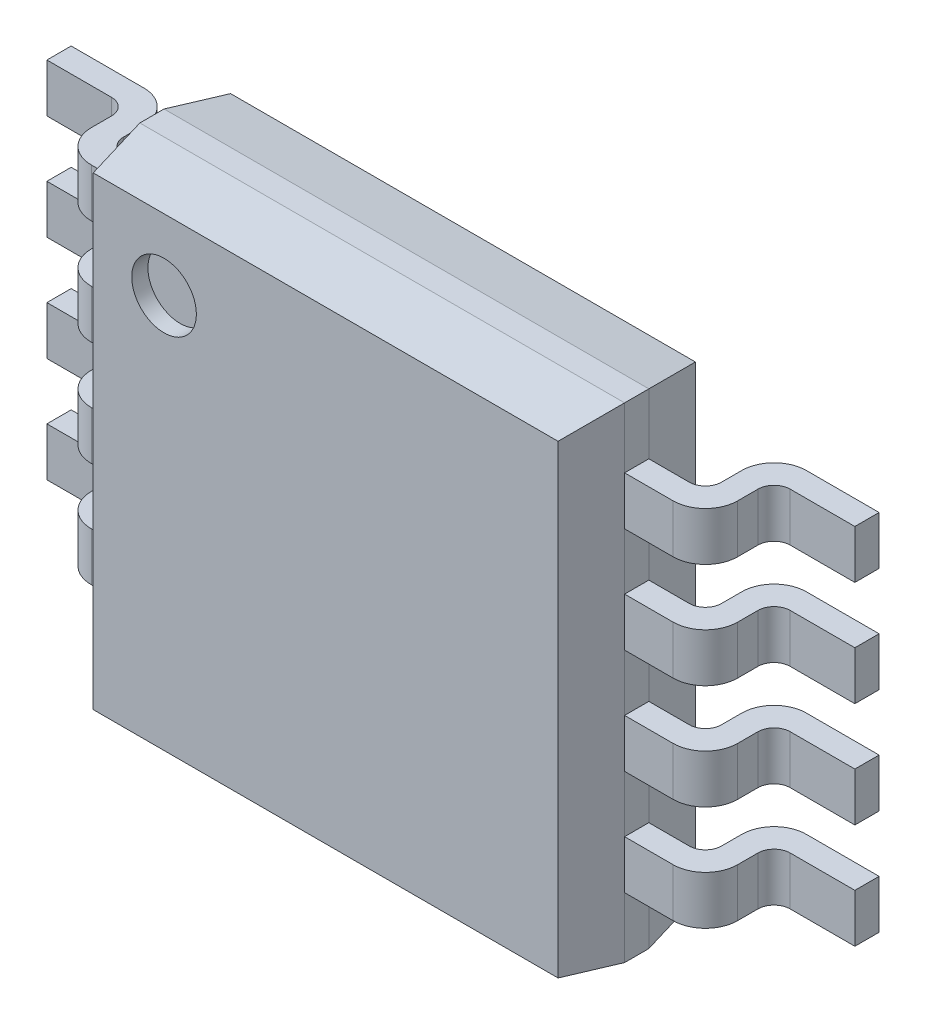
from build123d import *

# Parameters (mm, degrees)
SKETCH_1_W             = 3
SKETCH_1_H             = 3
EXTRUDE_1_DEPTH        = 0.85
CHAMFER_1_SIZE         = 0.35
CHAMFER_1_SIZE2        = 0.061714443
CHAMFER_1_PART_2_SIZE  = 0.35
CHAMFER_1_PART_2_SIZE2 = 0.061714443
CHAMFER_1_PART_3_SIZE  = 0.35
CHAMFER_1_PART_3_SIZE2 = 0.061714443
CHAMFER_1_PART_4_SIZE  = 0.35
CHAMFER_1_PART_4_SIZE2 = 0.061714443
EXTRUDE_2_DEPTH        = 0.15
PATTERN_LINEAR_1_COUNT = 4
PATTERN_LINEAR_1_PITCH = 0.65
SKETCH_4_R             = 0.2
CUT_EXTRUDE_1_DEPTH    = 0.1


with BuildPart() as part:
    # Эскиз1 → Бобышка-Вытянуть1 (new body)
    with BuildSketch(Plane.XY.offset(0.075)):
        Rectangle(SKETCH_1_W, SKETCH_1_H)
    extrude(amount=EXTRUDE_1_DEPTH)

    # Фаска1
    chamfer_1_edges = [part.edges().sort_by_distance(p)[0] for p in [
        (1.5, 0, 0.925),
        (1.5, 0, 0.075),
    ]]
    chamfer_1_side = [part.faces().sort_by_distance(p)[0] for p in [
        (1.5, 0, 0.5),
    ]]
    chamfer(chamfer_1_edges, length=CHAMFER_1_SIZE, length2=CHAMFER_1_SIZE2, reference=chamfer_1_side[0])

    # Фаска1 part 2
    chamfer_1_part_2_edges = [part.edges().sort_by_distance(p)[0] for p in [
        (0, 1.5, 0.925),
        (0, 1.5, 0.075),
    ]]
    chamfer_1_part_2_side = [part.faces().sort_by_distance(p)[0] for p in [
        (0, 1.5, 0.5),
    ]]
    chamfer(chamfer_1_part_2_edges, length=CHAMFER_1_PART_2_SIZE, length2=CHAMFER_1_PART_2_SIZE2, reference=chamfer_1_part_2_side[0])

    # Фаска1 part 3
    chamfer_1_part_3_edges = [part.edges().sort_by_distance(p)[0] for p in [
        (-1.5, 0, 0.925),
        (-1.5, 0, 0.075),
    ]]
    chamfer_1_part_3_side = [part.faces().sort_by_distance(p)[0] for p in [
        (-1.5, 0, 0.5),
    ]]
    chamfer(chamfer_1_part_3_edges, length=CHAMFER_1_PART_3_SIZE, length2=CHAMFER_1_PART_3_SIZE2, reference=chamfer_1_part_3_side[0])

    # Фаска1 part 4
    chamfer_1_part_4_edges = [part.edges().sort_by_distance(p)[0] for p in [
        (0, -1.5, 0.075),
        (0, -1.5, 0.925),
    ]]
    chamfer_1_part_4_side = [part.faces().sort_by_distance(p)[0] for p in [
        (0, -1.5, 0.5),
    ]]
    chamfer(chamfer_1_part_4_edges, length=CHAMFER_1_PART_4_SIZE, length2=CHAMFER_1_PART_4_SIZE2, reference=chamfer_1_part_4_side[0])

    # Эскиз3 → Бобышка-Вытянуть2 (add, symmetric)
    with BuildSketch(Plane(origin=(0, 0.975, 0), x_dir=(-1, 0, 0), z_dir=(0, 1, 0))):
        with BuildLine():
            Line((1.85, 0.325), (1.85, 0.2))
            ThreePointArc((1.85, 0.2), (1.908578644, 0.058578644), (2.05, 0))
            Line((2.05, 0), (2.5, 0))
            Line((2.5, 0), (2.5, 0.15))
            Line((2.5, 0.15), (2.1, 0.15))
            ThreePointArc((2.1, 0.15), (2.029289322, 0.179289322), (2, 0.25))
            Line((2, 0.25), (2, 0.375))
            ThreePointArc((2, 0.375), (1.941421356, 0.516421356), (1.8, 0.575))
            Line((1.8, 0.575), (1.5, 0.575))
            Line((1.5, 0.575), (1.5, 0.425))
            Line((1.5, 0.425), (1.75, 0.425))
            ThreePointArc((1.75, 0.425), (1.820710678, 0.395710678), (1.85, 0.325))
        make_face()
        with BuildLine():
            Line((-1.5, 0.425), (-1.5, 0.575))
            Line((-1.5, 0.575), (-1.8, 0.575))
            ThreePointArc((-1.8, 0.575), (-1.941421356, 0.516421356), (-2, 0.375))
            Line((-2, 0.375), (-2, 0.25))
            ThreePointArc((-2, 0.25), (-2.029289322, 0.179289322), (-2.1, 0.15))
            Line((-2.1, 0.15), (-2.5, 0.15))
            Line((-2.5, 0.15), (-2.5, 0))
            Line((-2.5, 0), (-2.05, 0))
            ThreePointArc((-2.05, 0), (-1.908578644, 0.058578644), (-1.85, 0.2))
            Line((-1.85, 0.2), (-1.85, 0.325))
            ThreePointArc((-1.85, 0.325), (-1.820710678, 0.395710678), (-1.75, 0.425))
            Line((-1.75, 0.425), (-1.5, 0.425))
        make_face()
    extrude_2 = extrude(amount=EXTRUDE_2_DEPTH, both=True)

    # Линейный массив1: Бобышка-Вытянуть2 ×4
    with Locations(*[(0, -i * PATTERN_LINEAR_1_PITCH, 0) for i in range(1, PATTERN_LINEAR_1_COUNT)]):
        add(extrude_2)

    # Эскиз4 → Вырез-Вытянуть1 (cut)
    with BuildSketch(Plane.XY.offset(0.925)):
        with Locations((-1, 1)):
            Circle(SKETCH_4_R)
    extrude(amount=-CUT_EXTRUDE_1_DEPTH, mode=Mode.SUBTRACT)


solid = part.part
